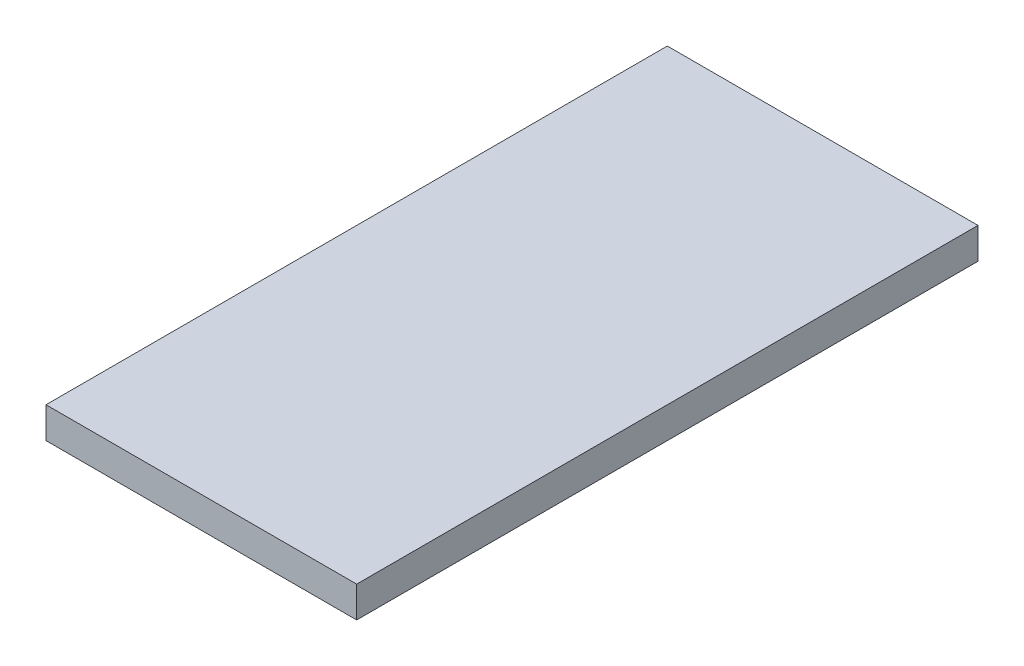
from build123d import *

# Parameters (mm, degrees)
SKETCH1_W           = 20
SKETCH1_H           = 40
BOSS_EXTRUDE1_DEPTH = 2


with BuildPart() as part:
    # Sketch1 → Boss-Extrude1 (new body)
    with BuildSketch(Plane(origin=(0, 0, 0), x_dir=(1, 0, 0), z_dir=(0, 1, 0))):
        Rectangle(SKETCH1_W, SKETCH1_H)
    extrude(amount=BOSS_EXTRUDE1_DEPTH)


solid = part.part
